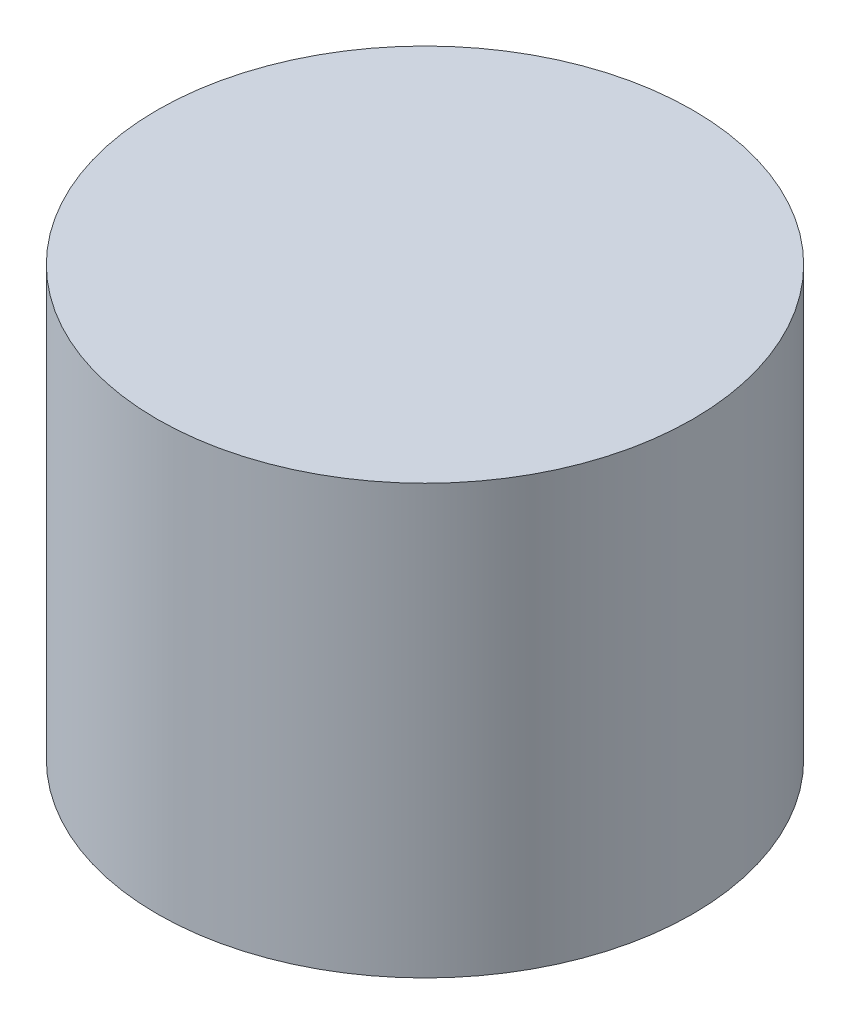
from build123d import *

# Parameters (mm, degrees)
SKETCH_1_R      = 2.5
EXTRUDE_1_DEPTH = 4


with BuildPart() as part:
    # 草图1 → 凸台-拉伸1 (new body)
    with BuildSketch(Plane(origin=(0, 0, 0), x_dir=(1, 0, 0), z_dir=(0, 1, 0))):
        Circle(SKETCH_1_R)
    extrude(amount=EXTRUDE_1_DEPTH)


solid = part.part
